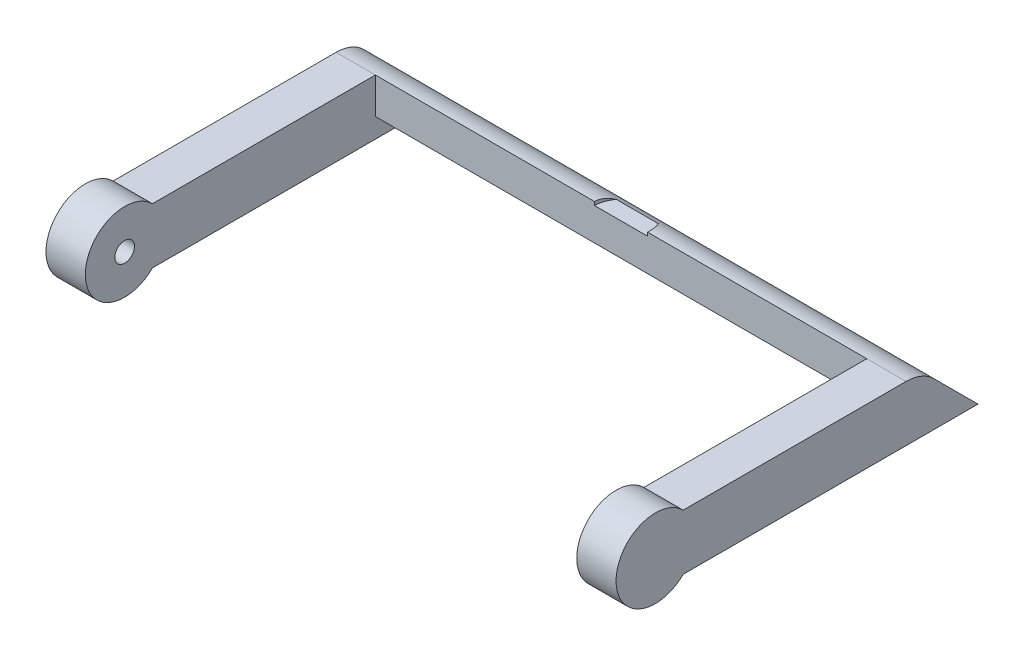
from build123d import *

# Parameters (mm, degrees)
SALIENTE_EXTRUIR1_DEPTH = 29
CORTAR_EXTRUIR1_DEPTH   = 14.5
CHAFL_N1_SIZE           = 1
CROQUIS3_R              = 0.5
CORTAR_EXTRUIR2_DEPTH   = 1
CROQUIS4_R              = 0.5
CORTAR_EXTRUIR3_DEPTH   = 1
CORTAR_EXTRUIR5_DEPTH   = 0.2


with BuildPart() as part:
    # Croquis1 → Saliente-Extruir1 (new body)
    with BuildSketch(Plane(origin=(0, 0, 0), x_dir=(0, 0, -1), z_dir=(1, 0, 0))):
        with BuildLine():
            Line((0, 0), (15, 0))
            Line((15, 0), (12.757359313, 2.242640687))
            ThreePointArc((12.757359313, 2.242640687), (12.108512615, 2.67618619), (11.343145751, 2.828427125))
            Line((11.343145751, 2.828427125), (0, 2.828427125))
            ThreePointArc((0, 2.828427125), (-3.414213562, 1.414213562), (0, 0))
        make_face()
    extrude(amount=SALIENTE_EXTRUIR1_DEPTH)

    # Croquis2 → Cortar-Extruir1 (cut, symmetric)
    with BuildSketch(Plane(origin=(0, 2.828427125, 0), x_dir=(1, 0, 0), z_dir=(0, 1, 0))):
        Polygon((2, 0), (2, 11.343145751), (27, 11.343145751), (27, 0), (27, -11.34659481), (2, -9.45811087), align=None)
    extrude(amount=CORTAR_EXTRUIR1_DEPTH, both=True, mode=Mode.SUBTRACT)

    # Chaflán1
    chafl_n1_edges = [part.edges().sort_by_distance(p)[0] for p in [
        (14.5, 0, -11.343145751),
    ]]
    chamfer(chafl_n1_edges, length=CHAFL_N1_SIZE)

    # Croquis3 → Cortar-Extruir2 (cut)
    with BuildSketch(Plane.ZY.offset(-27)):
        with Locations((1.414213562, 1.414213562)):
            Circle(CROQUIS3_R)
    extrude(amount=-CORTAR_EXTRUIR2_DEPTH, mode=Mode.SUBTRACT)

    # Croquis4 → Cortar-Extruir3 (cut)
    with BuildSketch(Plane(origin=(2, 0, 0), x_dir=(0, 0, -1), z_dir=(1, 0, 0))):
        with Locations((-1.414213562, 1.414213562)):
            Circle(CROQUIS4_R)
    extrude(amount=-CORTAR_EXTRUIR3_DEPTH, mode=Mode.SUBTRACT)

    # Croquis5 → Cortar-Extruir5 (cut)
    with BuildSketch(Plane(origin=(0, 2.85, 0), x_dir=(1, 0, 0), z_dir=(0, 1, 0))):
        with BuildLine():
            Line((13.15, 11.343145751), (15.85, 11.343145751))
            ThreePointArc((15.85, 11.343145751), (14.5, 12.693145751), (13.15, 11.343145751))
        make_face()
    extrude(amount=-CORTAR_EXTRUIR5_DEPTH, mode=Mode.SUBTRACT)


solid = part.part
